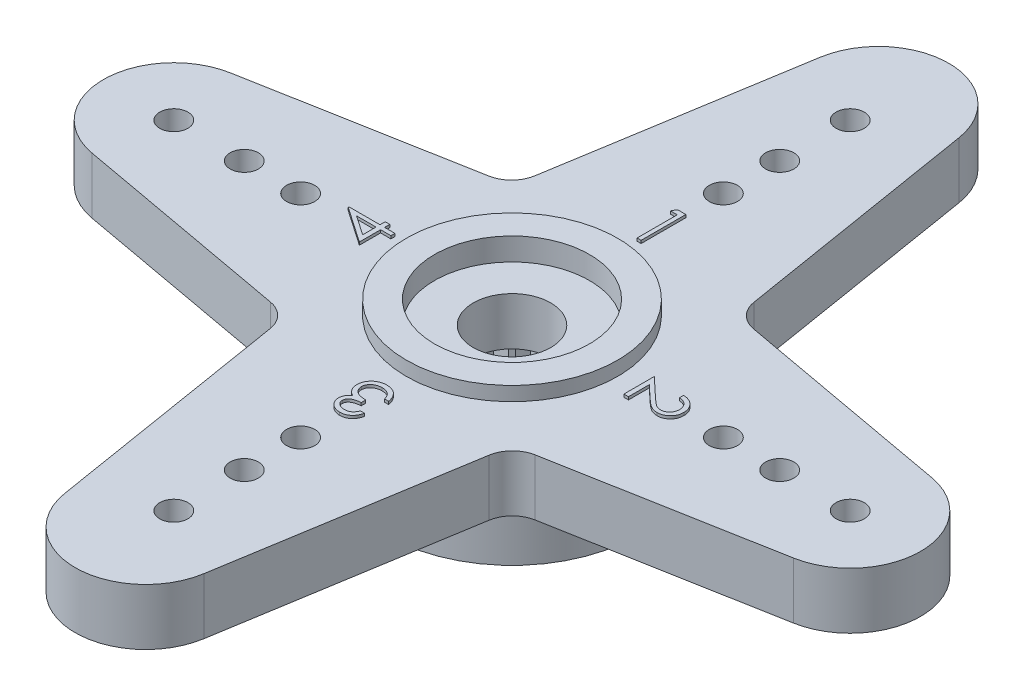
from build123d import *

# Parameters (mm, degrees)
SKETCH1_R           = 0.5
SKETCH1_R_2         = 1.375
BOSS_EXTRUDE1_DEPTH = 2
SKETCH2_R           = 3.75
SKETCH2_R_2         = 2.75
BOSS_EXTRUDE2_DEPTH = 0.5
SKETCH3_R           = 2.75
SKETCH3_R_2         = 1.375
CUT_EXTRUDE1_DEPTH  = 0.8
SKETCH4_R           = 4.5
SKETCH4_R_2         = 2.5
BOSS_EXTRUDE3_DEPTH = 2.5
CUT_EXTRUDE3_DEPTH  = 2.5
BOSS_EXTRUDE4_DEPTH = 0.1
FILLET1_R           = 1


with BuildPart() as part:
    # Sketch1 → Boss-Extrude1 (new body)
    with BuildSketch(Plane(origin=(0, 0, 0), x_dir=(1, 0, 0), z_dir=(0, 1, 0))):
        with BuildLine():
            Line((-4, 4), (-2.467435953, 13.402193757))
            ThreePointArc((-2.467435953, 13.402193757), (0, 15.5), (2.467435953, 13.402193757))
            Line((2.467435953, 13.402193757), (4, 4))
            Line((4, 4), (12.448472752, 2.459445505))
            ThreePointArc((12.448472752, 2.459445505), (14.5, 0), (12.448472752, -2.459445505))
            Line((12.448472752, -2.459445505), (4, -4))
            Line((4, -4), (2.467435953, -13.402193757))
            ThreePointArc((2.467435953, -13.402193757), (0, -15.5), (-2.467435953, -13.402193757))
            Line((-2.467435953, -13.402193757), (-4, -4))
            Line((-4, -4), (-12.448472752, -2.459445505))
            ThreePointArc((-12.448472752, -2.459445505), (-14.5, 0), (-12.448472752, 2.459445505))
            Line((-12.448472752, 2.459445505), (-4, 4))
        make_face()
        with Locations((0, 12)):
            Circle(SKETCH1_R, mode=Mode.SUBTRACT)
        with Locations((0, 9.5)):
            Circle(SKETCH1_R, mode=Mode.SUBTRACT)
        with Locations((0, 7.5)):
            Circle(SKETCH1_R, mode=Mode.SUBTRACT)
        with Locations((12, 0)):
            Circle(SKETCH1_R, mode=Mode.SUBTRACT)
        with Locations((9.5, 0)):
            Circle(SKETCH1_R, mode=Mode.SUBTRACT)
        with Locations((7.5, 0)):
            Circle(SKETCH1_R, mode=Mode.SUBTRACT)
        with Locations((0, -12)):
            Circle(SKETCH1_R, mode=Mode.SUBTRACT)
        with Locations((0, -9.5)):
            Circle(SKETCH1_R, mode=Mode.SUBTRACT)
        with Locations((0, -7.5)):
            Circle(SKETCH1_R, mode=Mode.SUBTRACT)
        with Locations((-12, 0)):
            Circle(SKETCH1_R, mode=Mode.SUBTRACT)
        with Locations((-9.5, 0)):
            Circle(SKETCH1_R, mode=Mode.SUBTRACT)
        with Locations((-7.5, 0)):
            Circle(SKETCH1_R, mode=Mode.SUBTRACT)
        Circle(SKETCH1_R_2, mode=Mode.SUBTRACT)
    extrude(amount=BOSS_EXTRUDE1_DEPTH)

    # Sketch2 → Boss-Extrude2 (add)
    with BuildSketch(Plane(origin=(0, 2, 0), x_dir=(1, 0, 0), z_dir=(0, 1, 0))):
        Circle(SKETCH2_R)
        Circle(SKETCH2_R_2, mode=Mode.SUBTRACT)
    extrude(amount=BOSS_EXTRUDE2_DEPTH)

    # Sketch3 → Cut-Extrude1 (cut)
    with BuildSketch(Plane(origin=(0, 2.5, 0), x_dir=(1, 0, 0), z_dir=(0, 1, 0))):
        Circle(SKETCH3_R)
        Circle(SKETCH3_R_2, mode=Mode.SUBTRACT)
    extrude(amount=-CUT_EXTRUDE1_DEPTH, mode=Mode.SUBTRACT)

    # Sketch4 → Boss-Extrude3 (add)
    with BuildSketch(Plane.XZ):
        Circle(SKETCH4_R)
        Circle(SKETCH4_R_2, mode=Mode.SUBTRACT)
    extrude(amount=BOSS_EXTRUDE3_DEPTH)

    # Sketch5 → Cut-Extrude3 (cut)
    with BuildSketch(Plane.XZ.offset(2.5)):
        with BuildLine():
            Line((0.299038106, 2.482050808), (0, 3))
            Line((0, 3), (-0.299038106, 2.482050808))
            ThreePointArc((-0.299038106, 2.482050808), (0, 2.5), (0.299038106, 2.482050808))
        make_face()
        with BuildLine():
            ThreePointArc((-1.051398019, 2.268162738), (-0.772542486, 2.377641291), (-0.482593741, 2.452978451))
            Line((-0.482593741, 2.452978451), (-0.927050983, 2.853169549))
            Line((-0.927050983, 2.853169549), (-1.051398019, 2.268162738))
        make_face()
        with BuildLine():
            Line((0.927050983, 2.853169549), (0.482593741, 2.452978451))
            ThreePointArc((0.482593741, 2.452978451), (0.772542486, 2.377641291), (1.051398019, 2.268162738))
            Line((1.051398019, 2.268162738), (0.927050983, 2.853169549))
        make_face()
        with BuildLine():
            ThreePointArc((-1.70083977, 1.832251096), (-1.469463131, 2.022542486), (-1.216985951, 2.183791473))
            Line((-1.216985951, 2.183791473), (-1.763355757, 2.427050983))
            Line((-1.763355757, 2.427050983), (-1.70083977, 1.832251096))
        make_face()
        with BuildLine():
            Line((1.763355757, 2.427050983), (1.216985951, 2.183791473))
            ThreePointArc((1.216985951, 2.183791473), (1.469463131, 2.022542486), (1.70083977, 1.832251096))
            Line((1.70083977, 1.832251096), (1.763355757, 2.427050983))
        make_face()
        with BuildLine():
            ThreePointArc((-2.183791473, 1.216985951), (-2.022542486, 1.469463131), (-1.832251096, 1.70083977))
            Line((-1.832251096, 1.70083977), (-2.427050983, 1.763355757))
            Line((-2.427050983, 1.763355757), (-2.183791473, 1.216985951))
        make_face()
        with BuildLine():
            Line((2.427050983, 1.763355757), (1.832251096, 1.70083977))
            ThreePointArc((1.832251096, 1.70083977), (2.022542486, 1.469463131), (2.183791473, 1.216985951))
            Line((2.183791473, 1.216985951), (2.427050983, 1.763355757))
        make_face()
        with BuildLine():
            ThreePointArc((-2.452978451, 0.482593741), (-2.377641291, 0.772542486), (-2.268162738, 1.051398019))
            Line((-2.268162738, 1.051398019), (-2.853169549, 0.927050983))
            Line((-2.853169549, 0.927050983), (-2.452978451, 0.482593741))
        make_face()
        with BuildLine():
            Line((2.853169549, 0.927050983), (2.268162738, 1.051398019))
            ThreePointArc((2.268162738, 1.051398019), (2.377641291, 0.772542486), (2.452978451, 0.482593741))
            Line((2.452978451, 0.482593741), (2.853169549, 0.927050983))
        make_face()
        with BuildLine():
            ThreePointArc((-2.482050808, -0.299038106), (-2.5, 0), (-2.482050808, 0.299038106))
            Line((-2.482050808, 0.299038106), (-3, 0))
            Line((-3, 0), (-2.482050808, -0.299038106))
        make_face()
        with BuildLine():
            Line((3, 0), (2.482050808, 0.299038106))
            ThreePointArc((2.482050808, 0.299038106), (2.5, 0), (2.482050808, -0.299038106))
            Line((2.482050808, -0.299038106), (3, 0))
        make_face()
        with BuildLine():
            ThreePointArc((-2.268162738, -1.051398019), (-2.377641291, -0.772542486), (-2.452978451, -0.482593741))
            Line((-2.452978451, -0.482593741), (-2.853169549, -0.927050983))
            Line((-2.853169549, -0.927050983), (-2.268162738, -1.051398019))
        make_face()
        with BuildLine():
            Line((2.853169549, -0.927050983), (2.452978451, -0.482593741))
            ThreePointArc((2.452978451, -0.482593741), (2.377641291, -0.772542486), (2.268162738, -1.051398019))
            Line((2.268162738, -1.051398019), (2.853169549, -0.927050983))
        make_face()
        with BuildLine():
            ThreePointArc((-1.832251096, -1.70083977), (-2.022542486, -1.469463131), (-2.183791473, -1.216985951))
            Line((-2.183791473, -1.216985951), (-2.427050983, -1.763355757))
            Line((-2.427050983, -1.763355757), (-1.832251096, -1.70083977))
        make_face()
        with BuildLine():
            Line((2.427050983, -1.763355757), (2.183791473, -1.216985951))
            ThreePointArc((2.183791473, -1.216985951), (2.022542486, -1.469463131), (1.832251096, -1.70083977))
            Line((1.832251096, -1.70083977), (2.427050983, -1.763355757))
        make_face()
        with BuildLine():
            ThreePointArc((-1.216985951, -2.183791473), (-1.469463131, -2.022542486), (-1.70083977, -1.832251096))
            Line((-1.70083977, -1.832251096), (-1.763355757, -2.427050983))
            Line((-1.763355757, -2.427050983), (-1.216985951, -2.183791473))
        make_face()
        with BuildLine():
            Line((1.763355757, -2.427050983), (1.70083977, -1.832251096))
            ThreePointArc((1.70083977, -1.832251096), (1.469463131, -2.022542486), (1.216985951, -2.183791473))
            Line((1.216985951, -2.183791473), (1.763355757, -2.427050983))
        make_face()
        with BuildLine():
            ThreePointArc((-0.482593741, -2.452978451), (-0.772542486, -2.377641291), (-1.051398019, -2.268162738))
            Line((-1.051398019, -2.268162738), (-0.927050983, -2.853169549))
            Line((-0.927050983, -2.853169549), (-0.482593741, -2.452978451))
        make_face()
        with BuildLine():
            Line((0.927050983, -2.853169549), (1.051398019, -2.268162738))
            ThreePointArc((1.051398019, -2.268162738), (0.772542486, -2.377641291), (0.482593741, -2.452978451))
            Line((0.482593741, -2.452978451), (0.927050983, -2.853169549))
        make_face()
        with BuildLine():
            ThreePointArc((0.299038106, -2.482050808), (0, -2.5), (-0.299038106, -2.482050808))
            Line((-0.299038106, -2.482050808), (0, -3))
            Line((0, -3), (0.299038106, -2.482050808))
        make_face()
    extrude(amount=-CUT_EXTRUDE3_DEPTH, mode=Mode.SUBTRACT)

    # Sketch6 → Boss-Extrude4 (add)
    with BuildSketch(Plane(origin=(0, 2, 0), x_dir=(1, 0, 0), z_dir=(0, 1, 0))):
        Polygon((-0.212111879, 6.0875), (0.081410256, 6.0875), (0.081410256, 4.5), (-0.061057692, 4.5), (-0.061057692, 5.924679487), (-0.305288462, 5.924679487), align=None)
        with BuildLine():
            Line((5.599038462, 0.34599359), (5.599038462, 0.488461538))
            add(Edge.make_bspline(
                [(5.599038462, 0.488461538), (5.617939279, 0.487533166), (5.655059981, 0.485709868), (5.709180577, 0.477167658), (5.760917347, 0.46495614), (5.809826741, 0.447649569), (5.856493025, 0.426277468), (5.900296523, 0.40011183), (5.941671981, 0.369710466), (5.979836023, 0.335129148), (6.014722729, 0.29760523), (6.045167992, 0.25736354), (6.070596953, 0.214817686), (6.091970581, 0.170336692), (6.107994605, 0.123406123), (6.119889389, 0.074474582), (6.127044708, 0.023320904), (6.12781392, -0.011531495), (6.128205128, -0.029256811)],
                knots=[0, 0, 0, 0, 5.6734e-05, 0.000111424, 0.000164104, 0.000216001, 0.000266797, 0.000317845, 0.000368792, 0.000420582, 0.000472116, 0.000522298, 0.000571655, 0.000620588, 0.000670069, 0.000720126, 0.000771487, 0.000824641, 0.000824641, 0.000824641, 0.000824641], degree=3))
            add(Edge.make_bspline(
                [(6.128205128, -0.029256811), (6.127797614, -0.046664009), (6.126996863, -0.080868531), (6.120120254, -0.130789516), (6.109349932, -0.178313503), (6.094239011, -0.223347597), (6.073926074, -0.265532491), (6.049525047, -0.305185086), (6.02130391, -0.342777454), (5.988078073, -0.376616959), (5.952607706, -0.407690267), (5.914739978, -0.434497361), (5.875628838, -0.457454046), (5.834976046, -0.476589172), (5.79239883, -0.490675349), (5.748517063, -0.501369751), (5.702876523, -0.507414685), (5.671985336, -0.50834243), (5.656280048, -0.508814103)],
                knots=[0, 0, 0, 0, 5.2201e-05, 0.000102573, 0.000150864, 0.00019823, 0.000244744, 0.000290994, 0.000337742, 0.000385422, 0.000432989, 0.000479051, 0.000524375, 0.000568907, 0.000613558, 0.00065868, 0.00070424, 0.000751358, 0.000751358, 0.000751358, 0.000751358], degree=3))
            add(Edge.make_bspline(
                [(5.656280048, -0.508814103), (5.634169423, -0.508046087), (5.590336183, -0.506523533), (5.525922299, -0.493499512), (5.463513856, -0.473158416), (5.413286579, -0.448666758), (5.372812816, -0.423959614), (5.339489511, -0.401694923), (5.30360953, -0.375630526), (5.265293024, -0.345387065), (5.224239863, -0.311590155), (5.180474849, -0.273933674), (5.134450153, -0.232149094), (5.103015113, -0.202821846), (5.086726262, -0.1876252)],
                knots=[0, 0, 0, 0, 6.6275e-05, 0.000131387, 0.000196351, 0.000262772, 0.00029844, 0.000338571, 0.000382971, 0.000431446, 0.00048499, 0.000542489, 0.000604632, 0.000671463, 0.000671463, 0.000671463, 0.000671463], degree=3))
            Line((5.086726262, -0.1876252), (4.662820513, 0.209567808))
            Line((4.662820513, 0.209567808), (4.662820513, -0.529166667))
            Line((4.662820513, -0.529166667), (4.5, -0.529166667))
            Line((4.5, -0.529166667), (4.5, 0.549519231))
            Line((4.5, 0.549519231), (5.15700621, -0.066145833))
            add(Edge.make_bspline(
                [(5.15700621, -0.066145833), (5.172652803, -0.081136472), (5.202706705, -0.10993042), (5.246597776, -0.15063927), (5.287268318, -0.187261175), (5.324898551, -0.219820431), (5.359275147, -0.248343825), (5.390667508, -0.272740096), (5.418806234, -0.293117072), (5.451862432, -0.31471242), (5.492269991, -0.335305017), (5.541401752, -0.353403803), (5.592090897, -0.364360562), (5.626334746, -0.36568164), (5.643559696, -0.366346154)],
                knots=[0, 0, 0, 0, 6.5005e-05, 0.000124862, 0.000179583, 0.000229184, 0.000274136, 0.000313574, 0.000348435, 0.000378338, 0.000431957, 0.000484068, 0.000535086, 0.000586722, 0.000586722, 0.000586722, 0.000586722], degree=3))
            add(Edge.make_bspline(
                [(5.643559696, -0.366346154), (5.654392812, -0.366060761), (5.675742806, -0.365498307), (5.707024672, -0.360440353), (5.737316681, -0.353009214), (5.766244292, -0.341555532), (5.794376458, -0.327794356), (5.820857871, -0.310213439), (5.846591221, -0.290123068), (5.87069413, -0.266819222), (5.892776139, -0.241235929), (5.912335573, -0.214204803), (5.928681993, -0.185607306), (5.94208205, -0.155562618), (5.952593749, -0.124154868), (5.959877459, -0.091323211), (5.964450586, -0.057158391), (5.965069336, -0.033829626), (5.965384615, -0.021942608)],
                knots=[0, 0, 0, 0, 3.2476e-05, 6.4004e-05, 9.4855e-05, 0.000125861, 0.000157149, 0.000188638, 0.00022102, 0.000254982, 0.000289027, 0.000322298, 0.000354918, 0.000387659, 0.000420845, 0.000454096, 0.000488413, 0.000524066, 0.000524066, 0.000524066, 0.000524066], degree=3))
            add(Edge.make_bspline(
                [(5.965384615, -0.021942608), (5.965060395, -0.009527925), (5.964423681, 0.014852462), (5.959967009, 0.050647099), (5.952285925, 0.084797422), (5.941755322, 0.117372561), (5.928497209, 0.148403903), (5.911665037, 0.177610862), (5.891915995, 0.205260088), (5.869403165, 0.231300798), (5.844219896, 0.255228126), (5.816492727, 0.276692883), (5.786041295, 0.295000051), (5.753553406, 0.311228532), (5.718165248, 0.323645722), (5.680734357, 0.334259816), (5.64072893, 0.341970171), (5.613166096, 0.344630175), (5.599038462, 0.34599359)],
                knots=[0, 0, 0, 0, 3.7241e-05, 7.3135e-05, 0.000108008, 0.0001421, 0.000175714, 0.000209044, 0.000243018, 0.000277511, 0.000312152, 0.000347072, 0.000382469, 0.000418593, 0.000455815, 0.00049478, 0.000535257, 0.00057782, 0.00057782, 0.00057782, 0.00057782], degree=3))
        make_face()
        with BuildLine():
            Line((0.34599359, -5.721153846), (0.488461538, -5.721153846))
            add(Edge.make_bspline(
                [(0.488461538, -5.721153846), (0.484601849, -5.737134294), (0.477056473, -5.768374763), (0.461318645, -5.813009485), (0.444173983, -5.855247654), (0.423586782, -5.894298373), (0.401131025, -5.930946447), (0.37540322, -5.964360657), (0.347590345, -5.995390823), (0.316826886, -6.022928613), (0.284564958, -6.04786494), (0.250349969, -6.069126127), (0.2148703, -6.08741601), (0.177880129, -6.102483759), (0.139269329, -6.113834621), (0.099386965, -6.122070029), (0.05812852, -6.127418142), (0.030121577, -6.127940095), (0.015900441, -6.128205128)],
                knots=[0, 0, 0, 0, 4.9287e-05, 9.6353e-05, 0.000141828, 0.000185921, 0.00022863, 0.000270609, 0.000312258, 0.000353458, 0.000394292, 0.00043444, 0.000474121, 0.000513923, 0.000554069, 0.000594671, 0.000636008, 0.000678651, 0.000678651, 0.000678651, 0.000678651], degree=3))
            add(Edge.make_bspline(
                [(0.015900441, -6.128205128), (-0.004819946, -6.127579549), (-0.045808747, -6.126342036), (-0.106026272, -6.115041559), (-0.164095579, -6.097159445), (-0.21938106, -6.072451719), (-0.270733706, -6.041977474), (-0.316424762, -6.005707754), (-0.355834908, -5.964342356), (-0.388897715, -5.918652943), (-0.414785304, -5.86982348), (-0.43387448, -5.819567694), (-0.445495743, -5.7680048), (-0.447001853, -5.733189891), (-0.44775641, -5.715747696)],
                knots=[0, 0, 0, 0, 6.211e-05, 0.000122866, 0.000183117, 0.000244047, 0.000304093, 0.000361803, 0.000418486, 0.000474973, 0.000530457, 0.000583793, 0.000635878, 0.00068817, 0.00068817, 0.00068817, 0.00068817], degree=3))
            add(Edge.make_bspline(
                [(-0.44775641, -5.715747696), (-0.447228639, -5.698962472), (-0.446195871, -5.666116392), (-0.437426655, -5.618164141), (-0.422669136, -5.572969558), (-0.402226779, -5.530342388), (-0.375764719, -5.490552907), (-0.343709603, -5.453511592), (-0.305835181, -5.419054153), (-0.277133663, -5.399314963), (-0.262357272, -5.389152644)],
                knots=[0, 0, 0, 0, 5.0327e-05, 9.8482e-05, 0.000145647, 0.000192584, 0.00023986, 0.000288564, 0.000339219, 0.000392971, 0.000392971, 0.000392971, 0.000392971], degree=3))
            add(Edge.make_bspline(
                [(-0.262357272, -5.389152644), (-0.279266057, -5.38102782), (-0.312821544, -5.364904106), (-0.358097689, -5.332780608), (-0.399825574, -5.296601576), (-0.422822908, -5.268052723), (-0.43440004, -5.253680889)],
                knots=[0, 0, 0, 0, 5.6181e-05, 0.00011149, 0.000165999, 0.000221257, 0.000221257, 0.000221257, 0.000221257], degree=3))
            add(Edge.make_bspline(
                [(-0.43440004, -5.253680889), (-0.442041901, -5.243223667), (-0.457200483, -5.222480465), (-0.475858316, -5.189110161), (-0.492978135, -5.155480456), (-0.505577827, -5.120269074), (-0.516450862, -5.084607067), (-0.523604956, -5.047730768), (-0.528197599, -5.009990535), (-0.5288425, -4.984446887), (-0.529166667, -4.971607071)],
                knots=[0, 0, 0, 0, 3.8818e-05, 7.7e-05, 0.000114547, 0.000151879, 0.000189009, 0.000226305, 0.000264409, 0.000302921, 0.000302921, 0.000302921, 0.000302921], degree=3))
            add(Edge.make_bspline(
                [(-0.529166667, -4.971607071), (-0.528350817, -4.94937866), (-0.526722958, -4.905026444), (-0.512235463, -4.839481871), (-0.489636803, -4.775530087), (-0.458141824, -4.71407805), (-0.418998333, -4.656756936), (-0.372686258, -4.605322495), (-0.319156288, -4.561514187), (-0.259966982, -4.524586511), (-0.195593193, -4.495321744), (-0.127013944, -4.474234108), (-0.05463527, -4.461584484), (-0.005138768, -4.460066765), (0.020034555, -4.459294872)],
                knots=[0, 0, 0, 0, 6.6613e-05, 0.000132912, 0.000200403, 0.000269665, 0.000339437, 0.000408104, 0.00047655, 0.00054626, 0.000616846, 0.000688063, 0.000760995, 0.000836477, 0.000836477, 0.000836477, 0.000836477], degree=3))
            add(Edge.make_bspline(
                [(0.020034555, -4.459294872), (0.037005812, -4.459692103), (0.070399587, -4.460473722), (0.11951096, -4.465721886), (0.166290723, -4.475567824), (0.211193125, -4.487950453), (0.253540479, -4.505070826), (0.293941914, -4.525481482), (0.332220335, -4.549705826), (0.36814842, -4.577784596), (0.401687783, -4.60921458), (0.431983954, -4.644517919), (0.459372127, -4.683035728), (0.48367828, -4.725114484), (0.50500471, -4.770636328), (0.52289247, -4.819783675), (0.538510693, -4.872175513), (0.545786309, -4.908676289), (0.549519231, -4.927403846)],
                knots=[0, 0, 0, 0, 5.0917e-05, 0.000100188, 0.000147899, 0.000194202, 0.000239731, 0.000284673, 0.000329844, 0.00037539, 0.000421283, 0.000467504, 0.000514711, 0.000562874, 0.000613093, 0.000665313, 0.000719655, 0.000776914, 0.000776914, 0.000776914, 0.000776914], degree=3))
            Line((0.549519231, -4.927403846), (0.407051282, -4.927403846))
            add(Edge.make_bspline(
                [(0.407051282, -4.927403846), (0.403339575, -4.915180544), (0.396119982, -4.891405159), (0.383830783, -4.857187592), (0.369829816, -4.825819475), (0.354809999, -4.797070701), (0.339035489, -4.770658147), (0.321384791, -4.747280228), (0.303165214, -4.725910119), (0.289431365, -4.713870241), (0.282709836, -4.707977764)],
                knots=[0, 0, 0, 0, 3.8321e-05, 7.4538e-05, 0.00010899, 0.000141279, 0.000171821, 0.000201141, 0.000229083, 0.000255865, 0.000255865, 0.000255865, 0.000255865], degree=3))
            add(Edge.make_bspline(
                [(0.282709836, -4.707977764), (0.273820396, -4.701127882), (0.256068955, -4.68744926), (0.227160407, -4.669943613), (0.196651098, -4.654959198), (0.164286602, -4.642779237), (0.130062577, -4.63363652), (0.094117851, -4.627056022), (0.056393446, -4.622711871), (0.030647277, -4.622317113), (0.017490485, -4.622115385)],
                knots=[0, 0, 0, 0, 3.3646e-05, 6.7188e-05, 0.000101179, 0.000135496, 0.000170751, 0.000207301, 0.000245053, 0.000284507, 0.000284507, 0.000284507, 0.000284507], degree=3))
            add(Edge.make_bspline(
                [(0.017490485, -4.622115385), (0.002634231, -4.622394287), (-0.026415892, -4.622939657), (-0.068801536, -4.627969629), (-0.109137453, -4.635263244), (-0.147012014, -4.646671877), (-0.182940598, -4.660358417), (-0.216121178, -4.678276609), (-0.247529219, -4.69851231), (-0.276244612, -4.722050322), (-0.302132943, -4.747492366), (-0.324503322, -4.774484107), (-0.343878628, -4.802188626), (-0.35945314, -4.831252213), (-0.371773311, -4.861389777), (-0.380155306, -4.892714125), (-0.385984774, -4.924961484), (-0.386459435, -4.946882168), (-0.386698718, -4.957932692)],
                knots=[0, 0, 0, 0, 4.455e-05, 8.7113e-05, 0.000127902, 0.000167348, 0.000205615, 0.000243028, 0.00028025, 0.00031755, 0.000354203, 0.000388976, 0.000422584, 0.000455451, 0.000487694, 0.00052002, 0.000552591, 0.000585702, 0.000585702, 0.000585702, 0.000585702], degree=3))
            add(Edge.make_bspline(
                [(-0.386698718, -4.957932692), (-0.386003169, -4.972723335), (-0.384615531, -5.002231023), (-0.374065118, -5.0456597), (-0.356555994, -5.087519235), (-0.332520572, -5.127261442), (-0.302560837, -5.163663871), (-0.268092983, -5.196247969), (-0.228381575, -5.223379244), (-0.191624295, -5.242072337), (-0.158981256, -5.254526807), (-0.131102444, -5.263260269), (-0.099863368, -5.270241472), (-0.06563939, -5.276994458), (-0.028286064, -5.282655717), (0.012230232, -5.287397248), (0.055925805, -5.291185256), (0.086174952, -5.292877803), (0.101762821, -5.29375)],
                knots=[0, 0, 0, 0, 4.4341e-05, 8.8462e-05, 0.000133228, 0.000180022, 0.000227256, 0.000274279, 0.000321825, 0.000371033, 0.00039761, 0.000426578, 0.00045859, 0.000493578, 0.000531223, 0.000571891, 0.000615941, 0.000662776, 0.000662776, 0.000662776, 0.000662776], degree=3))
            Line((0.101762821, -5.29375), (0.101762821, -5.456570513))
            add(Edge.make_bspline(
                [(0.101762821, -5.456570513), (0.082130288, -5.456953283), (0.043688426, -5.457702772), (-0.012623157, -5.464900992), (-0.066305692, -5.47658472), (-0.116551716, -5.492896722), (-0.162112282, -5.512755295), (-0.202016873, -5.53498931), (-0.234829912, -5.560639777), (-0.261139083, -5.588494162), (-0.280652882, -5.618558339), (-0.295056815, -5.64975068), (-0.303576438, -5.682651469), (-0.304715777, -5.70510004), (-0.305288462, -5.716383714)],
                knots=[0, 0, 0, 0, 5.8874e-05, 0.000115279, 0.000169985, 0.000223486, 0.00027347, 0.00031891, 0.000360133, 0.000397935, 0.000433304, 0.000467176, 0.00050065, 0.00053448, 0.00053448, 0.00053448, 0.00053448], degree=3))
            add(Edge.make_bspline(
                [(-0.305288462, -5.716383714), (-0.305104632, -5.724675376), (-0.304738912, -5.741171245), (-0.299942506, -5.765346601), (-0.293068021, -5.788783239), (-0.283080788, -5.811207319), (-0.270164259, -5.832690124), (-0.254537181, -5.853310117), (-0.236159971, -5.8732642), (-0.215151965, -5.892112288), (-0.191706493, -5.9090759), (-0.166764563, -5.924198724), (-0.140228938, -5.936914866), (-0.112272542, -5.947455684), (-0.082744259, -5.95537096), (-0.051799429, -5.961057912), (-0.019374439, -5.964612556), (0.002746995, -5.965124413), (0.013992388, -5.965384615)],
                knots=[0, 0, 0, 0, 2.4837e-05, 4.9413e-05, 7.3659e-05, 9.8004e-05, 0.000122819, 0.000148705, 0.000175488, 0.000204089, 0.000233221, 0.000262181, 0.000291481, 0.000321369, 0.000351687, 0.00038306, 0.000415685, 0.000449418, 0.000449418, 0.000449418, 0.000449418], degree=3))
            add(Edge.make_bspline(
                [(0.013992388, -5.965384615), (0.032068563, -5.964754757), (0.067375538, -5.963524498), (0.118264696, -5.952711076), (0.16552422, -5.935578323), (0.201526445, -5.914890575), (0.228156868, -5.894539373), (0.24755157, -5.877031234), (0.266250048, -5.85718059), (0.283518559, -5.83444296), (0.300391868, -5.809600201), (0.31670886, -5.782515486), (0.331945433, -5.752802669), (0.341220184, -5.73190776), (0.34599359, -5.721153846)],
                knots=[0, 0, 0, 0, 5.4175e-05, 0.000105816, 0.000155319, 0.000204466, 0.000229653, 0.000255773, 0.000282772, 0.000311332, 0.000341321, 0.000372844, 0.000406126, 0.000441419, 0.000441419, 0.000441419, 0.000441419], degree=3))
        make_face()
        Polygon((-6.128205128, 0.317054788), (-6.128205128, 0.34599359), (-5.029166667, 0.34599359), (-5.029166667, 0.529166667), (-4.866346154, 0.529166667), (-4.866346154, 0.34599359), (-4.5, 0.34599359), (-4.5, 0.203525641), (-4.866346154, 0.203525641), (-4.866346154, -0.549519231), align=None)
        Polygon((-5.029166667, 0.203525641), (-5.718609776, 0.203525641), (-5.029166667, -0.269671474), align=None, mode=Mode.SUBTRACT)
    extrude(amount=BOSS_EXTRUDE4_DEPTH)

    # Fillet1
    fillet1_edges = [part.edges().sort_by_distance(p)[0] for p in [
        (-4, 1, -4),
        (4, 1, -4),
        (4, 1, 4),
        (-4, 1, 4),
    ]]
    fillet(fillet1_edges, radius=FILLET1_R)


solid = part.part
